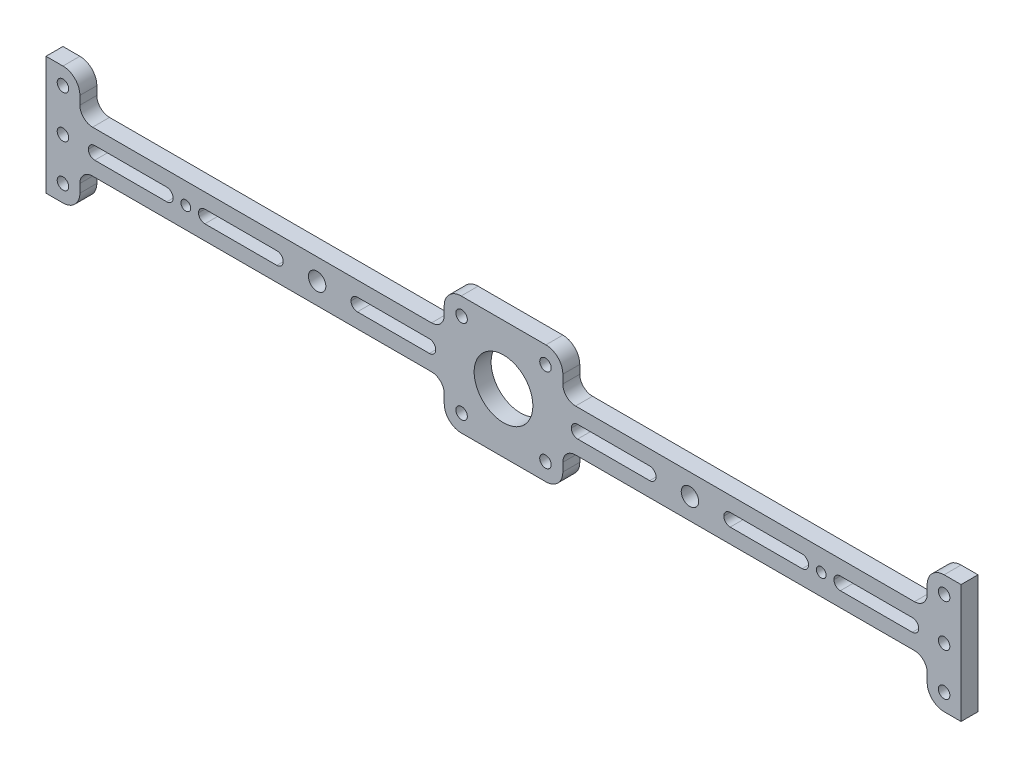
from build123d import *

# Parameters (mm, degrees)
SKETCH4_W                    = 136.525
SKETCH4_H                    = 15.875
SKETCH4_W_2                  = 44.45
SKETCH4_H_2                  = 14.2875
BOSS_EXTRUDE2_DEPTH          = 6.35
FILLET4_R                    = 4.7625
FILLET5_R                    = 6.35
CUT_EXTRUDE3_DEPTH           = 6.35
F_18_0_1695_DIAMETER_HOLE1_D = 4.3053
F_18_0_1695_DIAMETER_HOLE2_D = 4.3053
LPATTERN1_COUNT              = 2
LPATTERN1_PITCH              = 41.275
F_0_257_DIAMETER_HOLE1_D     = 6.5278
SKETCH5_R                    = 11
CUT_EXTRUDE4_DEPTH           = 7.35
LPATTERN2_COUNT              = 2
LPATTERN2_PITCH              = 98.425
MIRROR1_COPY_1_DEPTH         = 6.35
MIRROR1_COPY_2_DEPTH         = 6.35
SKETCH20_R                   = 1.8288
CUT_EXTRUDE5_DEPTH           = 7.35


with BuildPart() as part:
    # Sketch4 → Boss-Extrude2 (new body)
    with BuildSketch(Plane.XY):
        Polygon((-158.75, -22.225), (-158.75, -7.9375), (-158.75, 7.9375), (-158.75, 22.225), (-171.45, 22.225), (-171.45, -22.225), align=None)
        with Locations((-90.4875, 0)):
            Rectangle(SKETCH4_W, SKETCH4_H)
        with Locations((0, 15.08125)):
            Rectangle(SKETCH4_W_2, SKETCH4_H_2)
        Rectangle(SKETCH4_W_2, SKETCH4_H)
        with Locations((0, -15.08125)):
            Rectangle(SKETCH4_W_2, SKETCH4_H_2)
        with Locations((90.4875, 0)):
            Rectangle(SKETCH4_W, SKETCH4_H)
        Polygon((158.75, 7.9375), (158.75, -7.9375), (158.75, -22.225), (171.45, -22.225), (171.45, 22.225), (158.75, 22.225), align=None)
    extrude(amount=BOSS_EXTRUDE2_DEPTH)

    # Fillet4
    fillet4_edges = [part.edges().sort_by_distance(p)[0] for p in [
        (-158.75, 7.9375, 3.175),
        (-22.225, 7.9375, 3.175),
        (22.225, 7.9375, 3.175),
        (158.75, 7.9375, 3.175),
        (158.75, -7.9375, 3.175),
        (22.225, -7.9375, 3.175),
        (-22.225, -7.9375, 3.175),
        (-158.75, -7.9375, 3.175),
    ]]
    fillet(fillet4_edges, radius=FILLET4_R)

    # Fillet5
    fillet5_edges = [part.edges().sort_by_distance(p)[0] for p in [
        (-158.75, 22.225, 3.175),
        (-22.225, 22.225, 3.175),
        (22.225, 22.225, 3.175),
        (158.75, 22.225, 3.175),
        (158.75, -22.225, 3.175),
        (22.225, -22.225, 3.175),
        (-22.225, -22.225, 3.175),
        (-158.75, -22.225, 3.175),
    ]]
    fillet(fillet5_edges, radius=FILLET5_R)

    # Sketch7 → Cut-Extrude3 (cut)
    with BuildSketch(Plane.XY.offset(6.35)):
        with BuildLine():
            Line((-153.194004, 2.38125), (-126.205996004, 2.38125))
            ThreePointArc((-126.205996004, 2.38125), (-124.522377586, 1.683872418), (-123.825000004, 0.000254))
            ThreePointArc((-123.825000004, 0.000254), (-124.522377586, -1.683872418), (-126.205996004, -2.38125))
            Line((-126.205996004, -2.38125), (-153.194004, -2.38125))
            ThreePointArc((-153.194004, -2.38125), (-154.877622418, -1.683872418), (-155.575, 0.000254))
            ThreePointArc((-155.575, 0.000254), (-154.877622418, 1.683872418), (-153.194004, 2.38125))
        make_face()
    cut_extrude3 = extrude(amount=-CUT_EXTRUDE3_DEPTH, mode=Mode.SUBTRACT)

    # #18 (0.1695) Diameter Hole1 (through all)
    with Locations(Plane.XY.offset(6.35)):
        with Locations((-165.1, 15.875), (-165.1, 0), (-165.1, -15.875)):
            f_18_0_1695_diameter_hole1 = Hole(F_18_0_1695_DIAMETER_HOLE1_D / 2)

    # #18 (0.1695) Diameter Hole2 (through all)
    with Locations(Plane(origin=(0, 0, 0), x_dir=(-1, 0, 0), z_dir=(0, 0, -1))):
        with Locations((-15.715448212, -15.715448212), (-15.715448212, 15.715448212)):
            f_18_0_1695_diameter_hole2 = Hole(F_18_0_1695_DIAMETER_HOLE2_D / 2)

    # LPattern1: Cut-Extrude3 ×2
    with Locations(*[(i * LPATTERN1_PITCH, 0, 0) for i in range(1, LPATTERN1_COUNT)]):
        add(cut_extrude3, mode=Mode.SUBTRACT)

    # F (0.257) Diameter Hole1 (through all)
    with Locations(Plane(origin=(0, 0, 0), x_dir=(-1, 0, 0), z_dir=(0, 0, -1))):
        with Locations((-69.85, 0)):
            f_0_257_diameter_hole1 = Hole(F_0_257_DIAMETER_HOLE1_D / 2)

    # Sketch5 → Cut-Extrude4 (cut, through all)
    with BuildSketch(Plane.XY.offset(6.35)):
        Circle(SKETCH5_R)
    extrude(amount=-CUT_EXTRUDE4_DEPTH, mode=Mode.SUBTRACT)

    # LPattern2: Cut-Extrude3 ×2
    with Locations(*[(i * LPATTERN2_PITCH, 0, 0) for i in range(1, LPATTERN2_COUNT)]):
        add(cut_extrude3, mode=Mode.SUBTRACT)

    # Mirror1: #18 (0.1695) Diameter Hole2, #18 (0.1695) Diameter Hole1, F (0.257) Diameter Hole1, Cut-Extrude3 across plane
    add(f_18_0_1695_diameter_hole2.mirror(Plane(origin=(0, 0, 0), x_dir=(0, 0, 1), z_dir=(1, 0, 0))), mode=Mode.SUBTRACT)
    add(f_18_0_1695_diameter_hole1.mirror(Plane(origin=(0, 0, 0), x_dir=(0, 0, 1), z_dir=(1, 0, 0))), mode=Mode.SUBTRACT)
    add(f_0_257_diameter_hole1.mirror(Plane(origin=(0, 0, 0), x_dir=(0, 0, 1), z_dir=(1, 0, 0))), mode=Mode.SUBTRACT)
    add(cut_extrude3.mirror(Plane(origin=(0, 0, 0), x_dir=(0, 0, 1), z_dir=(1, 0, 0))), mode=Mode.SUBTRACT)

    # Mirror1 copy 1 sketch → Mirror1 copy 1 (cut)
    with BuildSketch(Plane(origin=(-98.425, 0, 6.35), x_dir=(-1, 0, 0), z_dir=(0, 0, 1))):
        with BuildLine():
            Line((-153.194004, -2.38125), (-126.205996004, -2.38125))
            ThreePointArc((-126.205996004, -2.38125), (-124.522377586, -1.683872418), (-123.825000004, -0.000254))
            ThreePointArc((-123.825000004, -0.000254), (-124.522377586, 1.683872418), (-126.205996004, 2.38125))
            Line((-126.205996004, 2.38125), (-153.194004, 2.38125))
            ThreePointArc((-153.194004, 2.38125), (-154.877622418, 1.683872418), (-155.575, -0.000254))
            ThreePointArc((-155.575, -0.000254), (-154.877622418, -1.683872418), (-153.194004, -2.38125))
        make_face()
    extrude(amount=-MIRROR1_COPY_1_DEPTH, mode=Mode.SUBTRACT)

    # Mirror1 copy 2 sketch → Mirror1 copy 2 (cut)
    with BuildSketch(Plane(origin=(-41.275, 0, 6.35), x_dir=(-1, 0, 0), z_dir=(0, 0, 1))):
        with BuildLine():
            Line((-153.194004, -2.38125), (-126.205996004, -2.38125))
            ThreePointArc((-126.205996004, -2.38125), (-124.522377586, -1.683872418), (-123.825000004, -0.000254))
            ThreePointArc((-123.825000004, -0.000254), (-124.522377586, 1.683872418), (-126.205996004, 2.38125))
            Line((-126.205996004, 2.38125), (-153.194004, 2.38125))
            ThreePointArc((-153.194004, 2.38125), (-154.877622418, 1.683872418), (-155.575, -0.000254))
            ThreePointArc((-155.575, -0.000254), (-154.877622418, -1.683872418), (-153.194004, -2.38125))
        make_face()
    extrude(amount=-MIRROR1_COPY_2_DEPTH, mode=Mode.SUBTRACT)

    # Sketch20 → Cut-Extrude5 (cut, through all)
    with BuildSketch(Plane(origin=(0, 0, 0), x_dir=(-1, 0, 0), z_dir=(0, 0, -1))):
        with Locations((-119.062500002, -0.000254)):
            Circle(SKETCH20_R)
    cut_extrude5 = extrude(amount=-CUT_EXTRUDE5_DEPTH, mode=Mode.SUBTRACT)

    # Mirror2: Cut-Extrude5 across plane
    add(cut_extrude5.mirror(Plane(origin=(0, 0, 0), x_dir=(0, 0, 1), z_dir=(1, 0, 0))), mode=Mode.SUBTRACT)


solid = part.part
